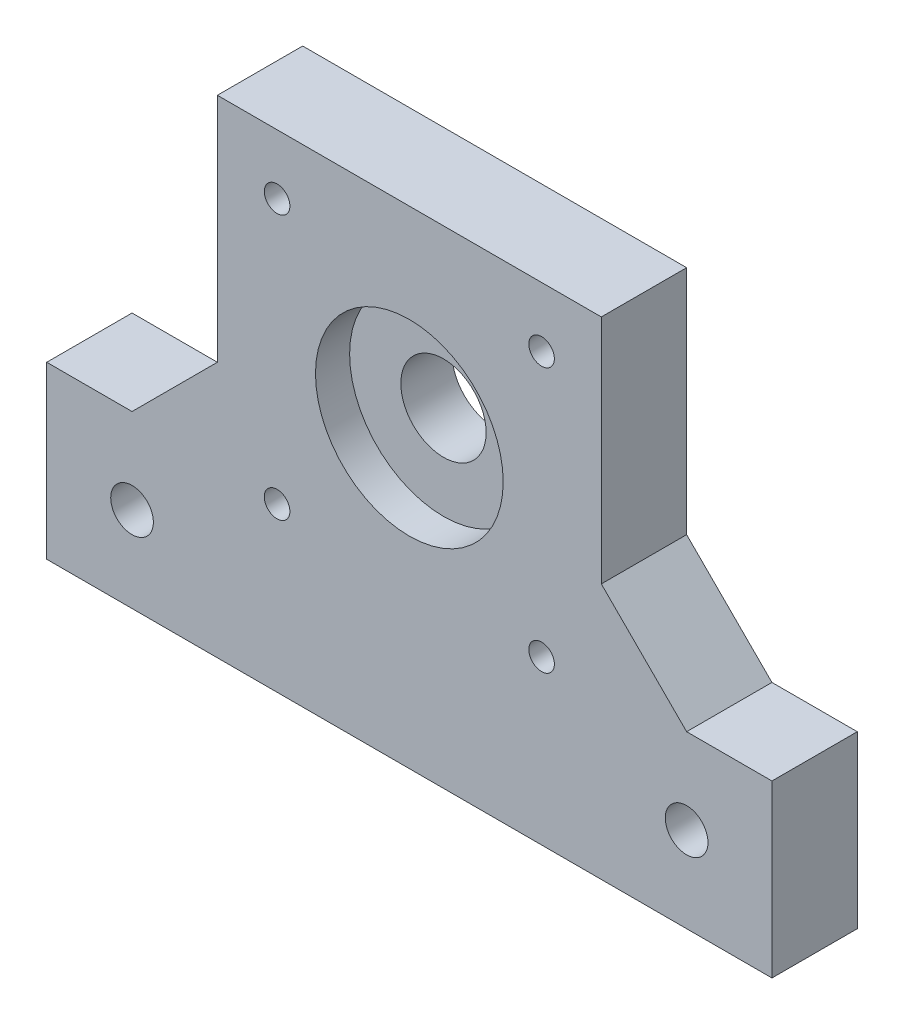
from build123d import *

# Parameters (mm, degrees)
SKETCH1_R           = 1.5
SKETCH1_R_2         = 2.5
SKETCH1_R_3         = 5
BOSS_EXTRUDE1_DEPTH = 10
SKETCH2_R           = 11
CUT_EXTRUDE1_DEPTH  = 4
CHAMFER1_SIZE       = 10
SKETCH3_R           = 2.85
CUT_EXTRUDE2_DEPTH  = 4


with BuildPart() as part:
    # Sketch1 → Boss-Extrude1 (new body)
    with BuildSketch(Plane.XY):
        Polygon((22.5, 22.5), (-22.5, 22.5), (-22.5, -14.6), (-42.5, -14.6), (-42.5, -34.6), (42.5, -34.6), (42.5, -14.6), (22.5, -14.6), align=None)
        with Locations((-15.5, 15.5)):
            Circle(SKETCH1_R, mode=Mode.SUBTRACT)
        with Locations((15.5, 15.5)):
            Circle(SKETCH1_R, mode=Mode.SUBTRACT)
        with Locations((32.5, -24.6)):
            Circle(SKETCH1_R_2, mode=Mode.SUBTRACT)
        with Locations((-32.5, -24.6)):
            Circle(SKETCH1_R_2, mode=Mode.SUBTRACT)
        Circle(SKETCH1_R_3, mode=Mode.SUBTRACT)
        with Locations((15.5, -15.5)):
            Circle(SKETCH1_R, mode=Mode.SUBTRACT)
        with Locations((-15.5, -15.5)):
            Circle(SKETCH1_R, mode=Mode.SUBTRACT)
    extrude(amount=BOSS_EXTRUDE1_DEPTH)

    # Sketch2 → Cut-Extrude1 (cut)
    with BuildSketch(Plane.XY.offset(10)):
        Circle(SKETCH2_R)
    extrude(amount=-CUT_EXTRUDE1_DEPTH, mode=Mode.SUBTRACT)

    # Chamfer1
    chamfer1_edges = [part.edges().sort_by_distance(p)[0] for p in [
        (22.5, -14.6, 5),
        (-22.5, -14.6, 5),
    ]]
    chamfer(chamfer1_edges, length=CHAMFER1_SIZE)

    # Sketch3 → Cut-Extrude2 (cut)
    with BuildSketch(Plane(origin=(0, 0, 0), x_dir=(-1, 0, 0), z_dir=(0, 0, -1))):
        with Locations((-15.5, 15.5)):
            Circle(SKETCH3_R)
        with Locations((15.5, 15.5)):
            Circle(SKETCH3_R)
        with Locations((-15.5, -15.5)):
            Circle(SKETCH3_R)
        with Locations((15.5, -15.5)):
            Circle(SKETCH3_R)
    extrude(amount=-CUT_EXTRUDE2_DEPTH, mode=Mode.SUBTRACT)


solid = part.part
